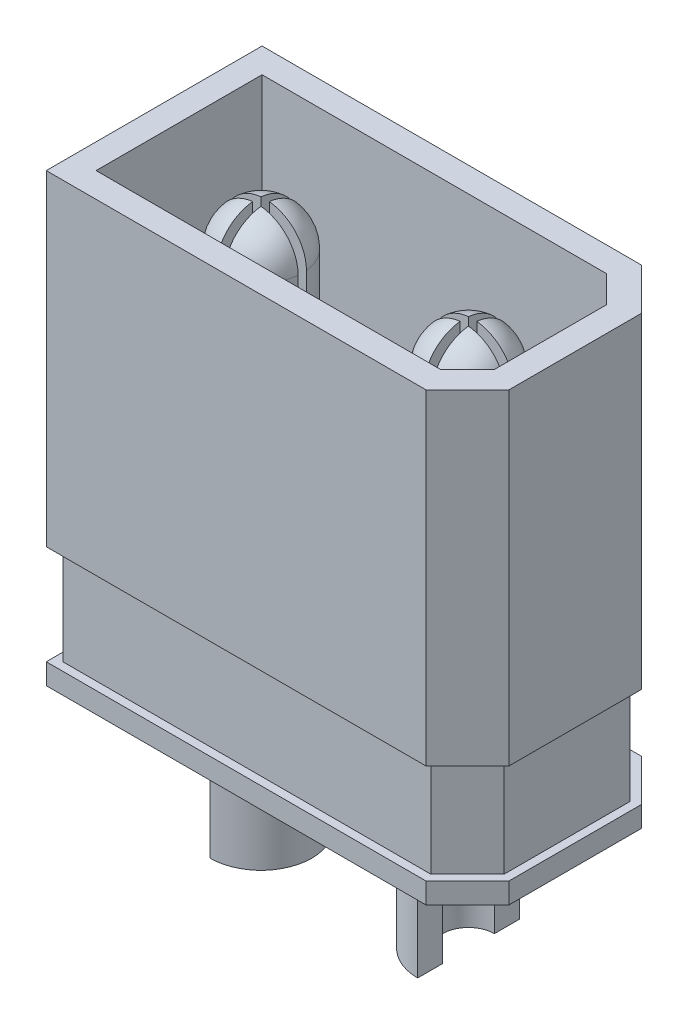
from build123d import *

# Parameters (mm, degrees)
SHAPE_DEPTH         = 10.75
CUT_EXTRUDE1_DEPTH  = 6.75
CUT_EXTRUDE2_REACH  = 6
FILLET1_R           = 0.2
SKETCH4_R           = 1
BOSS_EXTRUDE2_DEPTH = 6.1
FILLET2_R           = 1
SKETCH5_W           = 0.2
SKETCH5_H           = 2
SKETCH5_W_2         = 2
SKETCH5_H_2         = 0.2
CUT_EXTRUDE3_DEPTH  = 6.75
CUT_EXTRUDE4_DEPTH  = 2.4
CUT_EXTRUDE5_DEPTH  = 1
SKETCH7_R           = 1.225
SKETCH7_R_2         = 0.625
BOSS_EXTRUDE3_DEPTH = 4
SKETCH9_W           = 1.225
SKETCH9_H           = 2.45
CUT_EXTRUDE6_DEPTH  = 2.3


with BuildPart() as part:
    # Sketch1 → Shape (new body)
    with BuildSketch(Plane(origin=(0, 0, 0), x_dir=(1, 0, 0), z_dir=(0, 1, 0))):
        Polygon((5.075, -1.6), (5.075, 1.6), (4.075, 2.6), (-5.075, 2.6), (-5.075, -2.6), (4.075, -2.6), align=None)
    extrude(amount=SHAPE_DEPTH)

    # Sketch2 → Cut-Extrude1 (cut)
    with BuildSketch(Plane(origin=(0, 10.75, 0), x_dir=(1, 0, 0), z_dir=(0, 1, 0))):
        Polygon((3.826471863, -2), (4.475, -1.351471863), (4.475, 1.351471863), (3.826471863, 2), (-4.475, 2), (-4.475, -2), align=None)
    extrude(amount=-CUT_EXTRUDE1_DEPTH, mode=Mode.SUBTRACT)

    # Sketch3 → Cut-Extrude2 (cut, up to next)
    with BuildSketch(Plane(origin=(0, 4, 0), x_dir=(1, 0, 0), z_dir=(0, 1, 0)), mode=Mode.PRIVATE) as cut_extrude2_sk1:
        with BuildLine():
            Line((-1.675378875, -1.6), (1.675378875, -1.6))
            ThreePointArc((1.675378875, -1.6), (0.7, 0), (1.675378875, 1.6))
            Line((1.675378875, 1.6), (-1.675378875, 1.6))
            ThreePointArc((-1.675378875, 1.6), (-0.963068312, 0.936931688), (-0.7, 0))
            ThreePointArc((-0.7, 0), (-0.963068312, -0.936931688), (-1.675378875, -1.6))
        make_face()
    cut_extrude2_tool1 = extrude(cut_extrude2_sk1.sketch, amount=-CUT_EXTRUDE2_REACH, mode=Mode.PRIVATE) & part.part
    add(cut_extrude2_tool1.solids().sort_by_distance((0, 4, 0))[0], mode=Mode.SUBTRACT)

    # Fillet1
    fillet1_edges = [part.edges().sort_by_distance(p)[0] for p in [
        (1.675378875, 2, 1.6),
        (-1.675378875, 2, 1.6),
        (-1.675378875, 2, -1.6),
        (1.675378875, 2, -1.6),
    ]]
    fillet(fillet1_edges, radius=FILLET1_R)

    # Sketch4 → Boss-Extrude2 (add)
    with BuildSketch(Plane(origin=(0, 4, 0), x_dir=(1, 0, 0), z_dir=(0, 1, 0))):
        with Locations((-2.5, 0)):
            Circle(SKETCH4_R)
        with Locations((2.5, 0)):
            Circle(SKETCH4_R)
    extrude(amount=BOSS_EXTRUDE2_DEPTH)

    # Fillet2
    fillet2_edges = [part.edges().sort_by_distance(p)[0] for p in [
        (-3.5, 10.1, 0),
        (1.5, 10.1, 0),
    ]]
    fillet(fillet2_edges, radius=FILLET2_R)

    # Sketch5 → Cut-Extrude3 (cut)
    with BuildSketch(Plane(origin=(0, 10.75, 0), x_dir=(1, 0, 0), z_dir=(0, 1, 0))):
        with Locations((-2.5, 0)):
            Rectangle(SKETCH5_W, SKETCH5_H)
        with Locations((-2.5, 0)):
            Rectangle(SKETCH5_W_2, SKETCH5_H_2)
        with Locations((2.5, 0)):
            Rectangle(SKETCH5_W_2, SKETCH5_H_2)
        with Locations((2.5, 0)):
            Rectangle(SKETCH5_W, SKETCH5_H)
    extrude(amount=-CUT_EXTRUDE3_DEPTH, mode=Mode.SUBTRACT)

    # Sketch6 → Cut-Extrude4 (cut)
    with BuildSketch(Plane(origin=(0, 0.5, 0), x_dir=(-1, 0, 0), z_dir=(0, -1, 0))):
        Polygon((-5.075, -1.6), (-4.075, -2.6), (5.075, -2.6), (5.075, 2.6), (-4.075, 2.6), (-5.075, 1.6), align=None)
        Polygon((-4.875, -1.517157288), (-3.992157288, -2.4), (4.875, -2.4), (4.875, 2.4), (-3.992157288, 2.4), (-4.875, 1.517157288), align=None, mode=Mode.SUBTRACT)
    extrude(amount=-CUT_EXTRUDE4_DEPTH, mode=Mode.SUBTRACT)

    # Sketch8 → Cut-Extrude5 (cut)
    with BuildSketch(Plane.XZ):
        Polygon((-4.475, -2), (-4.475, 2), (3.826471863, 2), (4.475, 1.351471863), (4.475, -1.351471863), (3.826471863, -2), align=None)
    extrude(amount=-CUT_EXTRUDE5_DEPTH, mode=Mode.SUBTRACT)

    # Sketch7 → Boss-Extrude3 (add)
    with BuildSketch(Plane.XZ.offset(-1)):
        with Locations((-2.5, 0)):
            Circle(SKETCH7_R)
        with Locations((-2.5, 0)):
            Circle(SKETCH7_R_2, mode=Mode.SUBTRACT)
        with Locations((2.5, 0)):
            Circle(SKETCH7_R)
        with Locations((2.5, 0)):
            Circle(SKETCH7_R_2, mode=Mode.SUBTRACT)
    extrude(amount=BOSS_EXTRUDE3_DEPTH)

    # Sketch9 → Cut-Extrude6 (cut)
    with BuildSketch(Plane.XZ.offset(3)):
        with Locations((-3.1125, 0)):
            Rectangle(SKETCH9_W, SKETCH9_H)
        with Locations((3.1125, 0)):
            Rectangle(SKETCH9_W, SKETCH9_H)
    extrude(amount=-CUT_EXTRUDE6_DEPTH, mode=Mode.SUBTRACT)


solid = part.part
